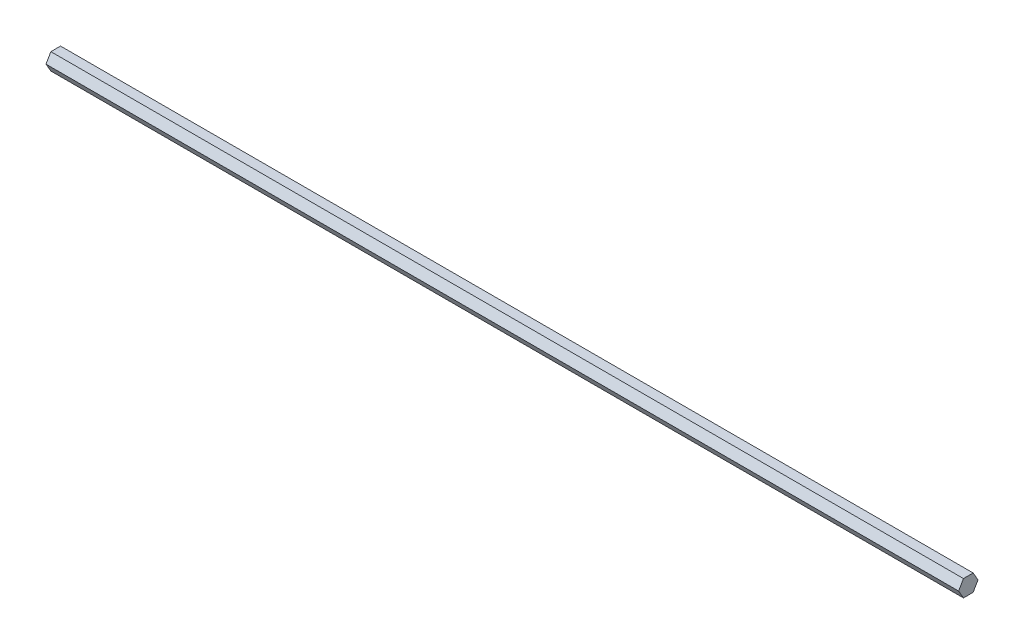
from build123d import *

# Parameters (mm, degrees)
BOSS_EXTRUDE1_DEPTH = 690.372


with BuildPart() as part:
    # Sketch1 → Boss-Extrude1 (new body)
    with BuildSketch(Plane(origin=(0, 0, 0), x_dir=(0, 0, -1), z_dir=(1, 0, 0))):
        Polygon((7.332348419, 0), (3.666174209, 6.35), (-3.666174209, 6.35), (-7.332348419, 0), (-3.666174209, -6.35), (3.666174209, -6.35), align=None)
    extrude(amount=BOSS_EXTRUDE1_DEPTH)


solid = part.part
